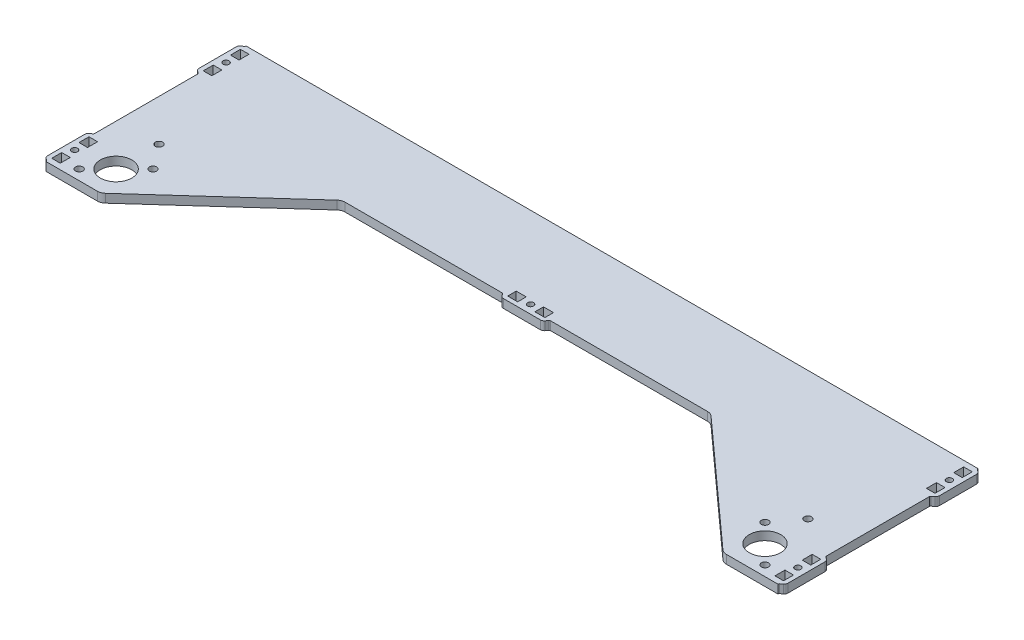
from build123d import *

# Parameters (mm, degrees)
SKETCH_1_R               = 2.55
EXTRUDE_1_DEPTH          = 6
SKETCH_7_R               = 11
SKETCH_7_R_2             = 2.55
CUT_EXTRUDE_1_DEPTH      = 14
CUT_EXTRUDE_1_DEPTH_BACK = 5
SKETCH_8_R               = 11
SKETCH_8_R_2             = 2.55
CUT_EXTRUDE_2_DEPTH      = 11
CUT_EXTRUDE_2_DEPTH_BACK = 5
EXTRUDE_2_DEPTH          = 6
SKETCH_3_R               = 2.1
SKETCH_3_W               = 7
SKETCH_3_H               = 6
CUT_EXTRUDE_12_DEPTH     = 7
EXTRUDE_21_DEPTH         = 6
SKETCH_31_R              = 2.1
SKETCH_31_W              = 7
SKETCH_31_H              = 6
CUT_EXTRUDE_13_DEPTH     = 7
EXTRUDE_22_DEPTH         = 6
SKETCH_32_R              = 2.1
SKETCH_32_W              = 7
SKETCH_32_H              = 6
CUT_EXTRUDE_14_DEPTH     = 7
EXTRUDE_23_DEPTH         = 6
SKETCH_33_R              = 2.1
SKETCH_33_W              = 7
SKETCH_33_H              = 6
CUT_EXTRUDE_15_DEPTH     = 7
EXTRUDE_24_DEPTH         = 6
SKETCH_34_R              = 2.1
SKETCH_34_W              = 7
SKETCH_34_H              = 6
CUT_EXTRUDE_16_DEPTH     = 7


with BuildPart() as part:
    # Эскиз1 → Бобышка-Вытянуть1 (new body)
    with BuildSketch(Plane(origin=(0, 0, 0), x_dir=(1, 0, 0), z_dir=(0, 1, 0))):
        with BuildLine():
            Line((-322.202898551, -260), (-322.202898551, -120))
            Line((-322.202898551, -120), (189.797101449, -120))
            Line((189.797101449, -120), (189.797101449, -260))
            Line((189.797101449, -260), (153.844946536, -260))
            ThreePointArc((153.844946536, -260), (151.691579542, -259.600268796), (149.825135208, -258.454336863))
            Line((149.825135208, -258.454336863), (64.602941314, -181.545663137))
            ThreePointArc((64.602941314, -181.545663137), (62.73649698, -180.399731204), (60.583129986, -180))
            Line((60.583129986, -180), (-192.988927088, -180))
            ThreePointArc((-192.988927088, -180), (-195.142294082, -180.399731204), (-197.008738416, -181.545663137))
            Line((-197.008738416, -181.545663137), (-282.230932309, -258.454336863))
            ThreePointArc((-282.230932309, -258.454336863), (-284.097376643, -259.600268796), (-286.250743637, -260))
            Line((-286.250743637, -260), (-322.202898551, -260))
        make_face()
        with Locations((-293.202898551, -210)):
            Circle(SKETCH_1_R, mode=Mode.SUBTRACT)
        with Locations((160.797101449, -210)):
            Circle(SKETCH_1_R, mode=Mode.SUBTRACT)
    extrude(amount=EXTRUDE_1_DEPTH)

    # Эскиз7 → Вырез-Вытянуть1 (cut, two sides)
    with BuildSketch(Plane(origin=(0, 0, 0), x_dir=(1, 0, 0), z_dir=(0, 1, 0))) as cut_extrude_1_sk:
        with Locations((-293.202898551, -240)):
            Circle(SKETCH_7_R)
        with Locations((-280.298199794, -227.095301243)):
            Circle(SKETCH_7_R_2)
        with Locations((-306.107597307, -252.904698757)):
            Circle(SKETCH_7_R_2)
    extrude(amount=CUT_EXTRUDE_1_DEPTH, mode=Mode.SUBTRACT)
    extrude(cut_extrude_1_sk.sketch, amount=-CUT_EXTRUDE_1_DEPTH_BACK, mode=Mode.SUBTRACT)

    # Эскиз8 → Вырез-Вытянуть2 (cut, two sides)
    with BuildSketch(Plane(origin=(0, 0, 0), x_dir=(1, 0, 0), z_dir=(0, 1, 0))) as cut_extrude_2_sk:
        with Locations((160.797101449, -240)):
            Circle(SKETCH_8_R)
        with Locations((147.892402692, -227.095301243)):
            Circle(SKETCH_8_R_2)
        with Locations((173.701800206, -252.904698757)):
            Circle(SKETCH_8_R_2)
    extrude(amount=CUT_EXTRUDE_2_DEPTH, mode=Mode.SUBTRACT)
    extrude(cut_extrude_2_sk.sketch, amount=-CUT_EXTRUDE_2_DEPTH_BACK, mode=Mode.SUBTRACT)

    # Эскиз2 → Бобышка-Вытянуть2 (add)
    with BuildSketch(Plane(origin=(139.797101449, 0, 243), x_dir=(0, 0, 1), z_dir=(0, 1, 0))):
        with BuildLine():
            Line((13, 53), (-13, 53))
            ThreePointArc((-13, 53), (-14.118033989, 52.736067977), (-15, 52))
            Line((-15, 52), (-16.2, 50.4))
            ThreePointArc((-16.2, 50.4), (-16.552786405, 50.105572809), (-17, 50))
            Line((-17, 50), (17, 50))
            ThreePointArc((17, 50), (16.552786405, 50.105572809), (16.2, 50.4))
            Line((16.2, 50.4), (15, 52))
            ThreePointArc((15, 52), (14.118033989, 52.736067977), (13, 53))
        make_face()
    extrude(amount=EXTRUDE_2_DEPTH)

    # Эскиз3 → Вырез-Вытянуть12 (cut, through all)
    with BuildSketch(Plane(origin=(139.797101449, 6, 243), x_dir=(0, 0, 1), z_dir=(0, 1, 0))):
        with Locations((0, 47)):
            Circle(SKETCH_3_R)
        with Locations((9.531849908, 47)):
            Rectangle(SKETCH_3_W, SKETCH_3_H)
        with Locations((-9.531849908, 47)):
            Rectangle(SKETCH_3_W, SKETCH_3_H)
    extrude(amount=-CUT_EXTRUDE_12_DEPTH, mode=Mode.SUBTRACT)

    # Эскиз21 → Бобышка-Вытянуть21 (add)
    with BuildSketch(Plane(origin=(139.797101449, 0, 137), x_dir=(0, 0, 1), z_dir=(0, 1, 0))):
        with BuildLine():
            Line((13, 53), (-13, 53))
            ThreePointArc((-13, 53), (-14.118033989, 52.736067977), (-15, 52))
            Line((-15, 52), (-16.2, 50.4))
            ThreePointArc((-16.2, 50.4), (-16.552786405, 50.105572809), (-17, 50))
            Line((-17, 50), (17, 50))
            ThreePointArc((17, 50), (16.552786405, 50.105572809), (16.2, 50.4))
            Line((16.2, 50.4), (15, 52))
            ThreePointArc((15, 52), (14.118033989, 52.736067977), (13, 53))
        make_face()
    extrude(amount=EXTRUDE_21_DEPTH)

    # Эскиз31 → Вырез-Вытянуть13 (cut, through all)
    with BuildSketch(Plane(origin=(139.797101449, 6, 137), x_dir=(0, 0, 1), z_dir=(0, 1, 0))):
        with Locations((0, 47)):
            Circle(SKETCH_31_R)
        with Locations((9.531849908, 47)):
            Rectangle(SKETCH_31_W, SKETCH_31_H)
        with Locations((-9.531849908, 47)):
            Rectangle(SKETCH_31_W, SKETCH_31_H)
    extrude(amount=-CUT_EXTRUDE_13_DEPTH, mode=Mode.SUBTRACT)

    # Эскиз22 → Бобышка-Вытянуть22 (add)
    with BuildSketch(Plane(origin=(-272.202898551, 0, 243), x_dir=(0, 0, -1), z_dir=(0, 1, 0))):
        with BuildLine():
            Line((13, 53), (-13, 53))
            ThreePointArc((-13, 53), (-14.118033989, 52.736067977), (-15, 52))
            Line((-15, 52), (-16.2, 50.4))
            ThreePointArc((-16.2, 50.4), (-16.552786405, 50.105572809), (-17, 50))
            Line((-17, 50), (17, 50))
            ThreePointArc((17, 50), (16.552786405, 50.105572809), (16.2, 50.4))
            Line((16.2, 50.4), (15, 52))
            ThreePointArc((15, 52), (14.118033989, 52.736067977), (13, 53))
        make_face()
    extrude(amount=EXTRUDE_22_DEPTH)

    # Эскиз32 → Вырез-Вытянуть14 (cut, through all)
    with BuildSketch(Plane(origin=(-272.202898551, 6, 243), x_dir=(0, 0, -1), z_dir=(0, 1, 0))):
        with Locations((0, 47)):
            Circle(SKETCH_32_R)
        with Locations((9.531849908, 47)):
            Rectangle(SKETCH_32_W, SKETCH_32_H)
        with Locations((-9.531849908, 47)):
            Rectangle(SKETCH_32_W, SKETCH_32_H)
    extrude(amount=-CUT_EXTRUDE_14_DEPTH, mode=Mode.SUBTRACT)

    # Эскиз23 → Бобышка-Вытянуть23 (add)
    with BuildSketch(Plane(origin=(-272.202898551, 0, 137), x_dir=(0, 0, -1), z_dir=(0, 1, 0))):
        with BuildLine():
            Line((13, 53), (-13, 53))
            ThreePointArc((-13, 53), (-14.118033989, 52.736067977), (-15, 52))
            Line((-15, 52), (-16.2, 50.4))
            ThreePointArc((-16.2, 50.4), (-16.552786405, 50.105572809), (-17, 50))
            Line((-17, 50), (17, 50))
            ThreePointArc((17, 50), (16.552786405, 50.105572809), (16.2, 50.4))
            Line((16.2, 50.4), (15, 52))
            ThreePointArc((15, 52), (14.118033989, 52.736067977), (13, 53))
        make_face()
    extrude(amount=EXTRUDE_23_DEPTH)

    # Эскиз33 → Вырез-Вытянуть15 (cut, through all)
    with BuildSketch(Plane(origin=(-272.202898551, 6, 137), x_dir=(0, 0, -1), z_dir=(0, 1, 0))):
        with Locations((0, 47)):
            Circle(SKETCH_33_R)
        with Locations((9.531849908, 47)):
            Rectangle(SKETCH_33_W, SKETCH_33_H)
        with Locations((-9.531849908, 47)):
            Rectangle(SKETCH_33_W, SKETCH_33_H)
    extrude(amount=-CUT_EXTRUDE_15_DEPTH, mode=Mode.SUBTRACT)

    # Эскиз24 → Бобышка-Вытянуть24 (add)
    with BuildSketch(Plane(origin=(-66.202898551, 0, 130), x_dir=(-1, 0, 0), z_dir=(0, 1, 0))):
        with BuildLine():
            Line((13, 53), (-13, 53))
            ThreePointArc((-13, 53), (-14.118033989, 52.736067977), (-15, 52))
            Line((-15, 52), (-16.2, 50.4))
            ThreePointArc((-16.2, 50.4), (-16.552786405, 50.105572809), (-17, 50))
            Line((-17, 50), (17, 50))
            ThreePointArc((17, 50), (16.552786405, 50.105572809), (16.2, 50.4))
            Line((16.2, 50.4), (15, 52))
            ThreePointArc((15, 52), (14.118033989, 52.736067977), (13, 53))
        make_face()
    extrude(amount=EXTRUDE_24_DEPTH)

    # Эскиз34 → Вырез-Вытянуть16 (cut, through all)
    with BuildSketch(Plane(origin=(-66.202898551, 6, 130), x_dir=(-1, 0, 0), z_dir=(0, 1, 0))):
        with Locations((0, 47)):
            Circle(SKETCH_34_R)
        with Locations((9.531849908, 47)):
            Rectangle(SKETCH_34_W, SKETCH_34_H)
        with Locations((-9.531849908, 47)):
            Rectangle(SKETCH_34_W, SKETCH_34_H)
    extrude(amount=-CUT_EXTRUDE_16_DEPTH, mode=Mode.SUBTRACT)


solid = part.part
